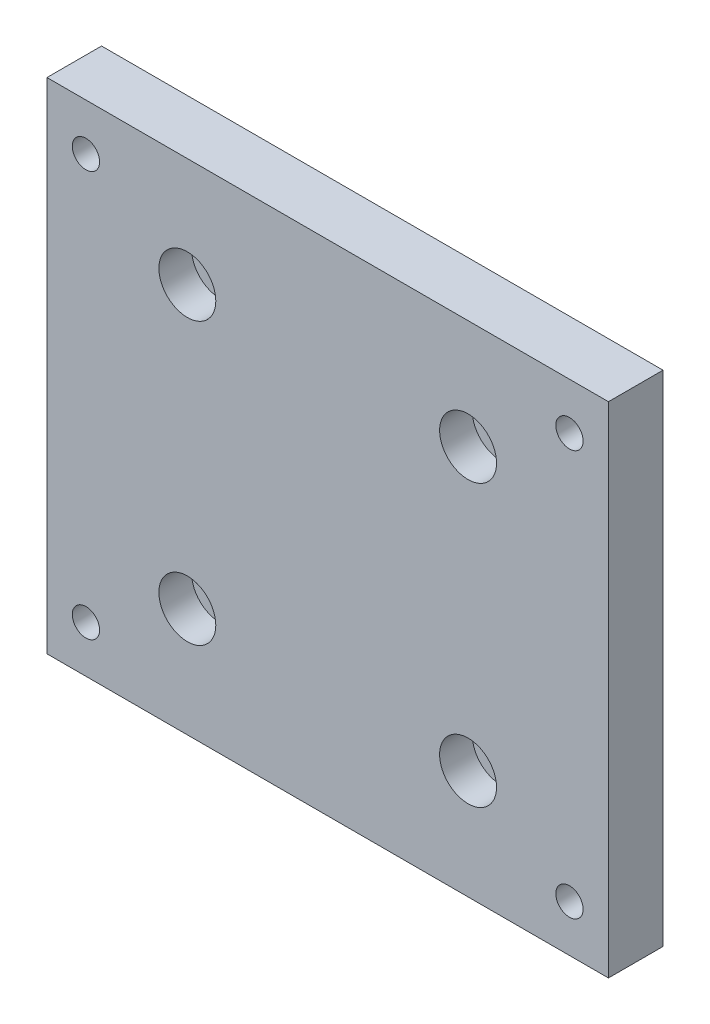
from build123d import *

# Parameters (mm, degrees)
SKETCH_2_W                = 72
SKETCH_2_H                = 64
SKETCH_2_R                = 2.25
SKETCH_2_R_2              = 1.75
EXTRUDE_1_DEPTH           = 7
HOLE_WIZARD_1_D           = 4.5
HOLE_WIZARD_1_CBORE_D     = 7.3
HOLE_WIZARD_1_CBORE_DEPTH = 4.2
CUT_EXTRUDE_1_DEPTH       = 2.5


with BuildPart() as part:
    # 草圖2 → 填料-伸長1 (new body)
    with BuildSketch(Plane.XY):
        Rectangle(SKETCH_2_W, SKETCH_2_H)
        with Locations((-18, 18)):
            Circle(SKETCH_2_R, mode=Mode.SUBTRACT)
        with Locations((-31, 26)):
            Circle(SKETCH_2_R_2, mode=Mode.SUBTRACT)
        with Locations((18, 18)):
            Circle(SKETCH_2_R, mode=Mode.SUBTRACT)
        with Locations((18, -18)):
            Circle(SKETCH_2_R, mode=Mode.SUBTRACT)
        with Locations((-18, -18)):
            Circle(SKETCH_2_R, mode=Mode.SUBTRACT)
        with Locations((31, 26)):
            Circle(SKETCH_2_R_2, mode=Mode.SUBTRACT)
        with Locations((31, -26)):
            Circle(SKETCH_2_R_2, mode=Mode.SUBTRACT)
        with Locations((-31, -26)):
            Circle(SKETCH_2_R_2, mode=Mode.SUBTRACT)
    extrude(amount=EXTRUDE_1_DEPTH)

    # 鑽孔1 (through all)
    with Locations(Plane(origin=(-18, 18, 7), x_dir=(1, 0, 0), z_dir=(0, 0, 1))):
        with Locations((0, 0), (36, 0), (36, -36), (0, -36)):
            CounterBoreHole(HOLE_WIZARD_1_D / 2, HOLE_WIZARD_1_CBORE_D / 2, HOLE_WIZARD_1_CBORE_DEPTH)

    # 草圖4 → 除料-伸長1 (cut)
    with BuildSketch(Plane(origin=(0, 0, 0), x_dir=(-1, 0, 0), z_dir=(0, 0, -1))):
        Polygon((-27.709103466, 26), (-29.354551733, 28.85), (-32.645448267, 28.85), (-34.290896534, 26), (-32.645448267, 23.15), (-29.354551733, 23.15), align=None)
        Polygon((29.354551733, 23.15), (27.709103466, 26), (29.354551733, 28.85), (32.645448267, 28.85), (34.290896534, 26), (32.645448267, 23.15), align=None)
        Polygon((27.709103466, -26), (29.354551733, -28.85), (32.645448267, -28.85), (34.290896534, -26), (32.645448267, -23.15), (29.354551733, -23.15), align=None)
        Polygon((-29.354551733, -23.15), (-27.709103466, -26), (-29.354551733, -28.85), (-32.645448267, -28.85), (-34.290896534, -26), (-32.645448267, -23.15), align=None)
    extrude(amount=-CUT_EXTRUDE_1_DEPTH, mode=Mode.SUBTRACT)


solid = part.part
